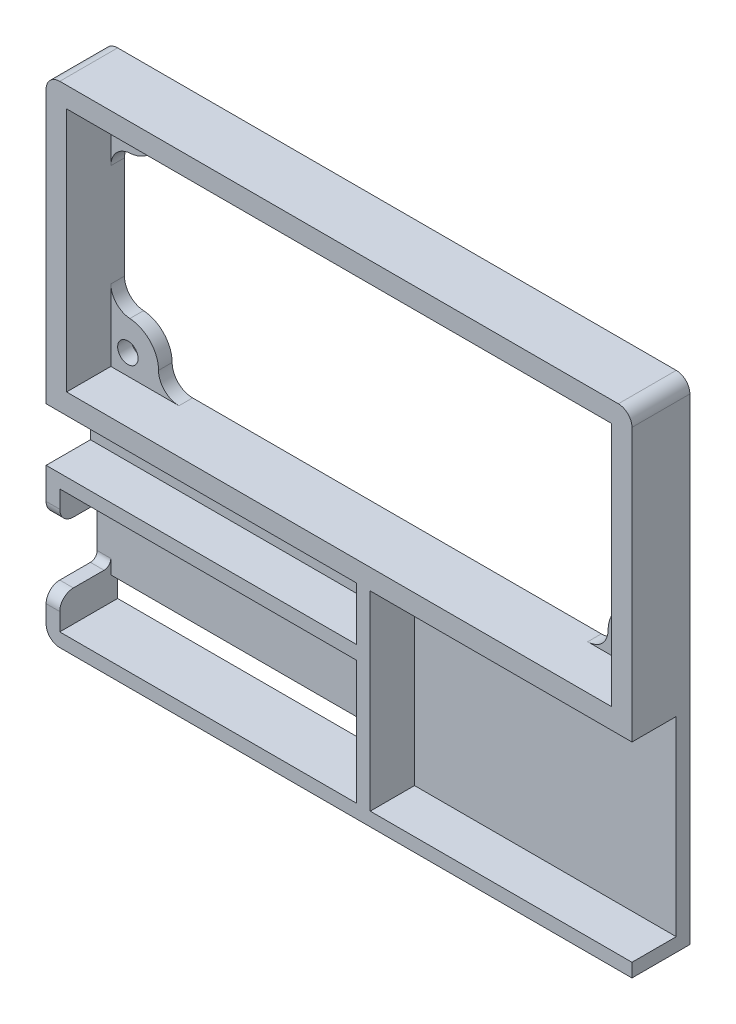
from build123d import *

# Parameters (mm, degrees)
BOSS_EXTRUDE1_DEPTH = 7.5
SKETCH2_W           = 2
SKETCH2_H           = 9
BOSS_EXTRUDE2_DEPTH = 1
SKETCH3_W           = 38.42
SKETCH3_H           = 2
SKETCH3_W_2         = 86
SKETCH3_H_2         = 42
SKETCH3_W_3         = 80
SKETCH3_H_3         = 36
BOSS_EXTRUDE3_DEPTH = 8.5
SKETCH3_3_R         = 1.5
SKETCH3_3_W         = 47.58
SKETCH3_3_H         = 7.82
BOSS_EXTRUDE4_DEPTH = 2
FILLET1_R           = 3
FILLET2_R           = 2
SKETCH6_W           = 2
SKETCH6_H           = 7.82
BOSS_EXTRUDE5_DEPTH = 6.5
FILLET3_R           = 1
FILLET4_R           = 2


with BuildPart() as part:
    # Sketch1 → Boss-Extrude1 (new body)
    with BuildSketch(Plane.XY):
        Polygon((-2, -2), (-2, 4.59), (0, 4.59), (0, 0), (43.58, 0), (43.58, 18.18), (0, 18.18), (0, 13.59), (-2, 13.59), (-2, 20.18), (45.58, 20.18), (45.58, -2), align=None)
    extrude(amount=BOSS_EXTRUDE1_DEPTH)

    # Sketch2 → Boss-Extrude2 (add)
    with BuildSketch(Plane(origin=(0, 0, 0), x_dir=(-1, 0, 0), z_dir=(0, 0, -1))):
        with Locations((1, 9.09)):
            Rectangle(SKETCH2_W, SKETCH2_H)
        Polygon((0, 4.59), (0, 13.59), (0, 14.68), (-43.58, 14.68), (-43.58, 3.5), (0, 3.5), align=None)
        Polygon((2, 13.59), (2, 20.18), (-45.58, 20.18), (-45.58, -2), (2, -2), (2, 4.59), (0, 4.59), (0, 3.5), (0, 0), (-43.58, 0), (-43.58, 3.5), (-43.58, 14.68), (-43.58, 18.18), (0, 18.18), (0, 14.68), (0, 13.59), align=None)
    extrude(amount=BOSS_EXTRUDE2_DEPTH)

    # Sketch3 → Boss-Extrude3 (add)
    with BuildSketch(Plane(origin=(0, 0, -1), x_dir=(-1, 0, 0), z_dir=(0, 0, -1))):
        with Locations((-64.79, -1)):
            Rectangle(SKETCH3_W, SKETCH3_H)
        with Locations((-41, 49)):
            Rectangle(SKETCH3_W_2, SKETCH3_H_2)
        with Locations((-41, 49)):
            Rectangle(SKETCH3_W_3, SKETCH3_H_3, mode=Mode.SUBTRACT)
    extrude(amount=-BOSS_EXTRUDE3_DEPTH)

    # Sketch3_3 → Boss-Extrude4 (add)
    with BuildSketch(Plane(origin=(0, 0, -1), x_dir=(-1, 0, 0), z_dir=(0, 0, -1))):
        with BuildLine():
            Line((-6.854101966, 31), (-1, 31))
            Line((-1, 31), (-1, 37.741657387))
            ThreePointArc((-1, 37.741657387), (-6.897772597, 36.950447657), (-6.854101966, 31))
        make_face()
        with Locations((-3.5, 34)):
            Circle(SKETCH3_3_R, mode=Mode.SUBTRACT)
        with BuildLine():
            ThreePointArc((-6.854101966, 67), (-6.897772597, 61.049552343), (-1, 60.258342613))
            Line((-1, 60.258342613), (-1, 67))
            Line((-1, 67), (-6.854101966, 67))
        make_face()
        with Locations((-3.5, 64)):
            Circle(SKETCH3_3_R, mode=Mode.SUBTRACT)
        with BuildLine():
            Line((-81, 67), (-81, 60.258342613))
            ThreePointArc((-81, 60.258342613), (-75.102227403, 61.049552343), (-75.145898034, 67))
            Line((-75.145898034, 67), (-81, 67))
        make_face()
        with Locations((-78.5, 64)):
            Circle(SKETCH3_3_R, mode=Mode.SUBTRACT)
        with BuildLine():
            Line((-81, 31), (-75.145898034, 31))
            ThreePointArc((-75.145898034, 31), (-75.102227403, 36.950447657), (-81, 37.741657387))
            Line((-81, 37.741657387), (-81, 31))
        make_face()
        with Locations((-78.5, 34)):
            Circle(SKETCH3_3_R, mode=Mode.SUBTRACT)
        with Locations((-21.79, 24.09)):
            Rectangle(SKETCH3_3_W, SKETCH3_3_H)
        Polygon((-84, 0), (-45.58, 0), (-45.58, 20.18), (-45.58, 28), (-84, 28), align=None)
    extrude(amount=-BOSS_EXTRUDE4_DEPTH)

    # Fillet1
    fillet1_edges = [part.edges().sort_by_distance(p)[0] for p in [
        (1, 37.741657387, 0),
        (6.854101966, 31, 0),
        (6.854101966, 67, 0),
        (1, 60.258342613, 0),
        (81, 60.258342613, 0),
        (75.145898034, 67, 0),
        (75.145898034, 31, 0),
        (81, 37.741657387, 0),
    ]]
    fillet(fillet1_edges, radius=FILLET1_R)

    # Fillet2
    fillet2_edges = [part.edges().sort_by_distance(p)[0] for p in [
        (-2, -2, 3.25),
        (-2, 70, 3.25),
        (84, 70, 3.25),
    ]]
    fillet(fillet2_edges, radius=FILLET2_R)

    # Sketch6 → Boss-Extrude5 (add)
    with BuildSketch(Plane.XY.offset(1)):
        with Locations((44.58, 24.09)):
            Rectangle(SKETCH6_W, SKETCH6_H)
    extrude(amount=BOSS_EXTRUDE5_DEPTH)

    # Fillet3
    fillet3_edges = [part.edges().sort_by_distance(p)[0] for p in [
        (-1, 4.59, 0),
        (-1, 13.59, 0),
    ]]
    fillet(fillet3_edges, radius=FILLET3_R)

    # Fillet4
    fillet4_edges = [part.edges().sort_by_distance(p)[0] for p in [
        (-1, 4.59, 7.5),
        (-1, 13.59, 7.5),
    ]]
    fillet(fillet4_edges, radius=FILLET4_R)


solid = part.part
